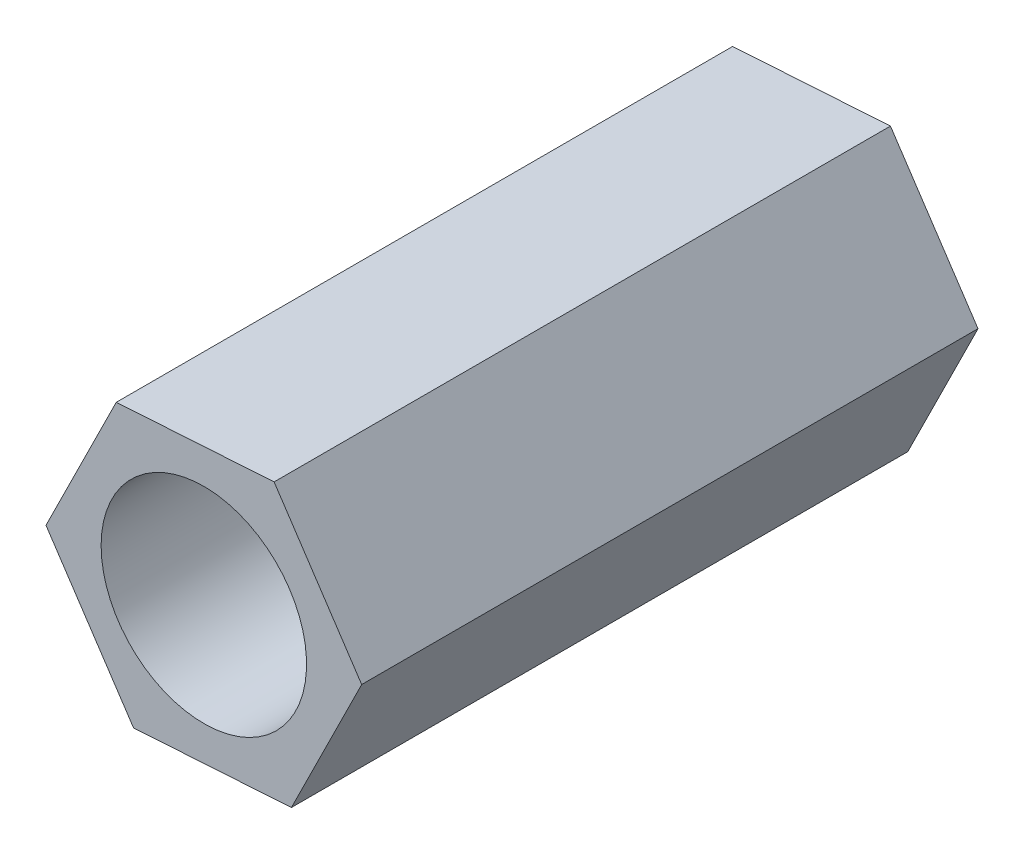
from build123d import *

# Parameters (mm, degrees)
EXTRUDE_1_DEPTH     = 9
SKETCH_2_R          = 1.5
CUT_EXTRUDE_1_DEPTH = 10


with BuildPart() as part:
    # 草图1 → 凸台-拉伸1 (new body)
    with BuildSketch(Plane.XY):
        Polygon((1.026274392, 2.068838854), (-1.278529808, 1.923199122), (-2.3048042, -0.145639732), (-1.026274392, -2.068838854), (1.278529808, -1.923199122), (2.3048042, 0.145639732), align=None)
    extrude(amount=EXTRUDE_1_DEPTH)

    # 草图2 → 切除-拉伸1 (cut, through all)
    with BuildSketch(Plane(origin=(0, 0, 0), x_dir=(-1, 0, 0), z_dir=(0, 0, -1))):
        Circle(SKETCH_2_R)
    extrude(amount=-CUT_EXTRUDE_1_DEPTH, mode=Mode.SUBTRACT)


solid = part.part
